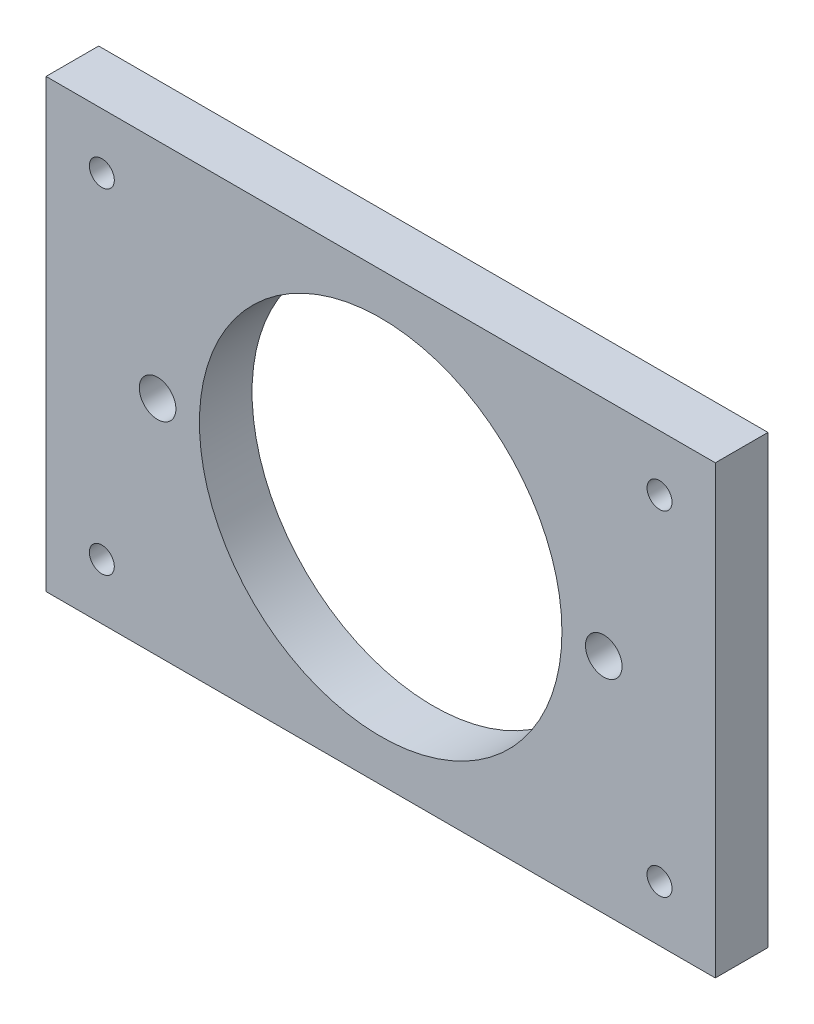
from build123d import *

# Parameters (mm, degrees)
SKETCH1_W           = 76.2
SKETCH1_H           = 50.8
SKETCH1_R           = 20.6375
SKETCH1_R_2         = 2.0828
SKETCH1_R_3         = 1.4224
BOSS_EXTRUDE1_DEPTH = 5.9944


with BuildPart() as part:
    # Sketch1 → Boss-Extrude1 (new body)
    with BuildSketch(Plane.XY):
        Rectangle(SKETCH1_W, SKETCH1_H)
        Circle(SKETCH1_R, mode=Mode.SUBTRACT)
        with Locations((-25.4, 0)):
            Circle(SKETCH1_R_2, mode=Mode.SUBTRACT)
        with Locations((25.4, 0)):
            Circle(SKETCH1_R_2, mode=Mode.SUBTRACT)
        with Locations((-31.75, 19.05)):
            Circle(SKETCH1_R_3, mode=Mode.SUBTRACT)
        with Locations((-31.75, -19.05)):
            Circle(SKETCH1_R_3, mode=Mode.SUBTRACT)
        with Locations((31.75, -19.05)):
            Circle(SKETCH1_R_3, mode=Mode.SUBTRACT)
        with Locations((31.75, 19.05)):
            Circle(SKETCH1_R_3, mode=Mode.SUBTRACT)
    extrude(amount=BOSS_EXTRUDE1_DEPTH)


solid = part.part
